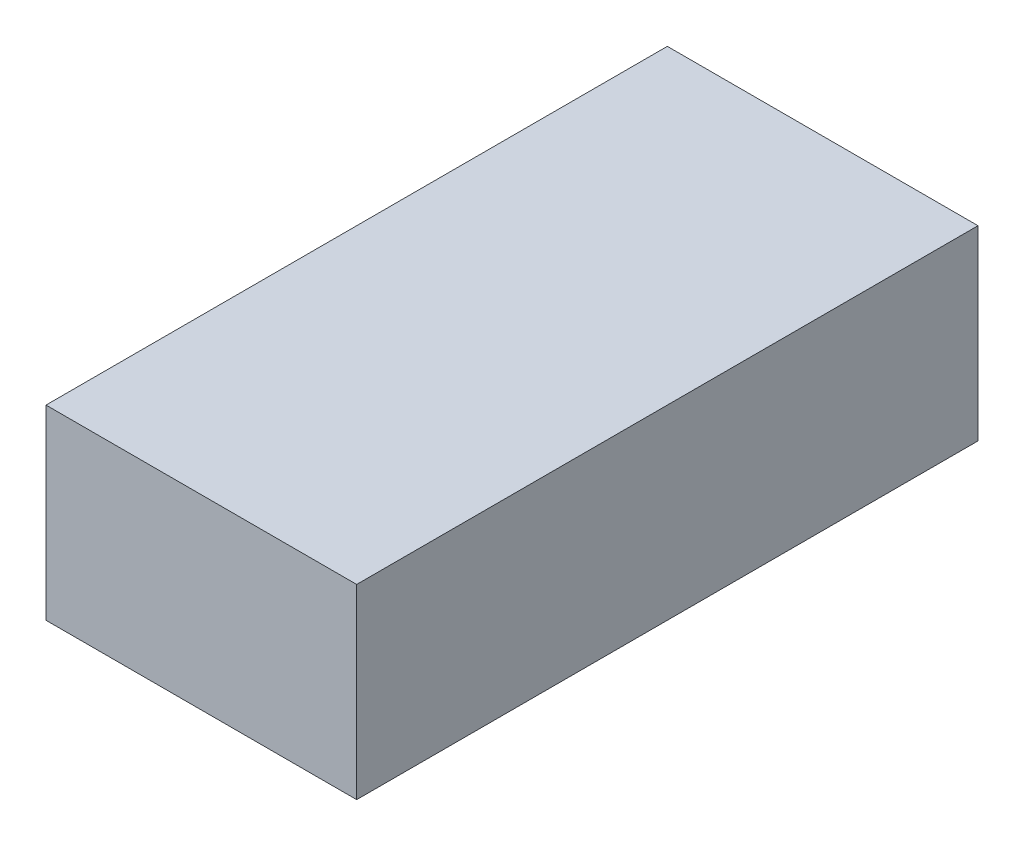
from build123d import *

# Parameters (mm, degrees)
BOSS_EXTRUDE1_DEPTH = 69
SKETCH4_W           = 15
SKETCH4_H           = 188.2
BOSS_EXTRUDE2_DEPTH = 61.9
BOSS_EXTRUDE3_DEPTH = 20.4
FILLET1_R           = 10
SKETCH6_W           = 10000
SKETCH6_H           = 3000
BOSS_EXTRUDE4_DEPTH = 2500


with BuildPart() as part:
    # Sketch2 → Boss-Extrude1 (new body, symmetric)
    with BuildSketch(Plane(origin=(0, 0, 0), x_dir=(0, 0, -1), z_dir=(1, 0, 0))):
        with BuildLine():
            Line((-262.793626597, 0), (0, 0))
            Line((0, 0), (203.2, 0))
            Line((203.2, 0), (203.2, 81.9))
            Line((203.2, 81.9), (188.2, 81.9))
            Line((188.2, 81.9), (188.2, 20))
            Line((188.2, 20), (0, 20))
            Line((0, 20), (0, 133.7))
            Line((0, 133.7), (-115, 133.7))
            Line((-115, 133.7), (-171.193830238, 94.352656466))
            Line((-171.193830238, 94.352656466), (-262.793626597, 81.479144628))
            Line((-262.793626597, 81.479144628), (-262.793626597, 31.479144628))
            ThreePointArc((-262.793626597, 31.479144628), (-272.644060375, 15.739572314), (-262.793626597, 0))
        make_face()
    extrude(amount=BOSS_EXTRUDE1_DEPTH, both=True)

    # Sketch4 → Boss-Extrude2 (add)
    with BuildSketch(Plane(origin=(0, 20, 0), x_dir=(1, 0, 0), z_dir=(0, 1, 0))):
        with Locations((61.5, 94.1)):
            Rectangle(SKETCH4_W, SKETCH4_H)
    boss_extrude2 = extrude(amount=BOSS_EXTRUDE2_DEPTH)

    # Mirror1: Boss-Extrude2 across plane
    add(boss_extrude2.mirror(Plane(origin=(0, 0, 0), x_dir=(0, 0, 1), z_dir=(1, 0, 0))))

    # Sketch5 → Boss-Extrude3 (add)
    with BuildSketch(Plane(origin=(69, 0, 0), x_dir=(0, 0, -1), z_dir=(1, 0, 0))):
        with BuildLine():
            Line((-224.944060375, 0), (-160.344060375, 0))
            ThreePointArc((-160.344060375, 0), (-192.644060375, -32.3), (-224.944060375, 0))
        make_face()
        with BuildLine():
            Line((28.055939625, 0), (92.655939625, 0))
            ThreePointArc((92.655939625, 0), (60.355939625, -32.3), (28.055939625, 0))
        make_face()
    boss_extrude3 = extrude(amount=-BOSS_EXTRUDE3_DEPTH)

    # Mirror2: Boss-Extrude3 across plane
    add(boss_extrude3.mirror(Plane(origin=(0, 0, 0), x_dir=(0, 0, 1), z_dir=(1, 0, 0))))

    # Fillet1
    fillet1_edges = [part.edges().sort_by_distance(p)[0] for p in [
        (0, 31.479144628, 262.793626597),
        (0, 81.479144628, 262.793626597),
        (0, 94.352656466, 171.193830238),
        (0, 133.7, 115),
        (0, 133.7, 0),
    ]]
    fillet(fillet1_edges, radius=FILLET1_R)


with BuildPart() as body_2:
    # Sketch6 → Boss-Extrude4 (new body, symmetric)
    with BuildSketch(Plane(origin=(0, 0, 0), x_dir=(0, 0, -1), z_dir=(1, 0, 0))):
        with Locations((2727.48649749, 1467.7)):
            Rectangle(SKETCH6_W, SKETCH6_H)
    extrude(amount=BOSS_EXTRUDE4_DEPTH, both=True)


solid = Compound([part.part, body_2.part])
